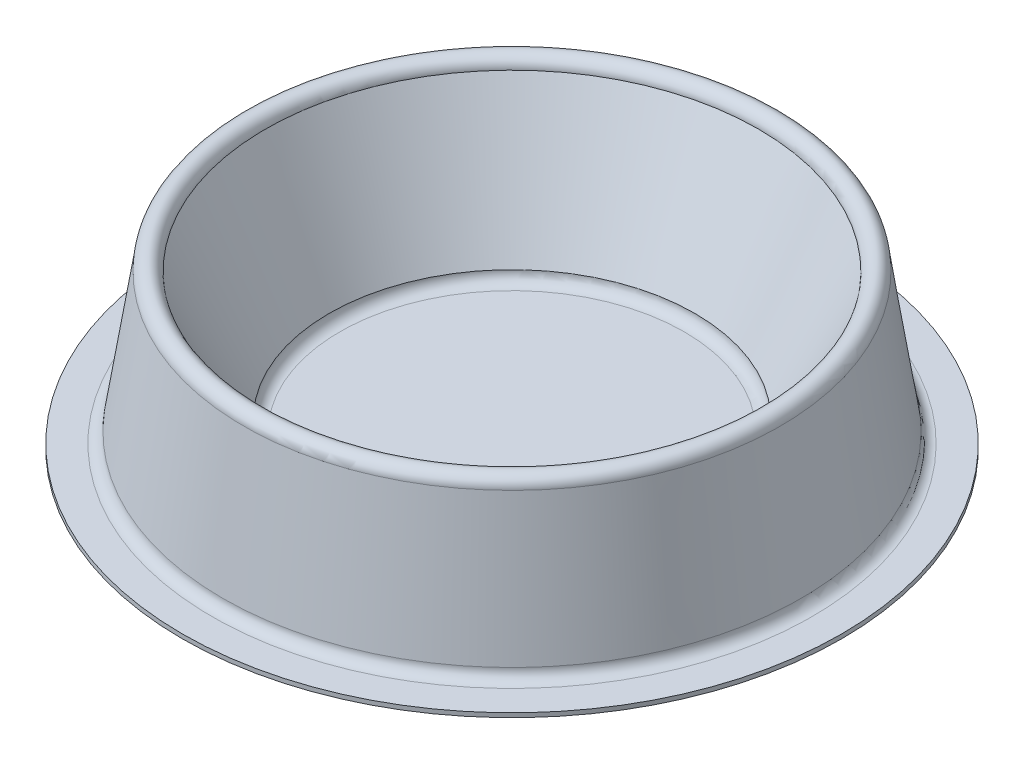
from build123d import *


with BuildPart() as part:
    # Sketch1 → Revolve-Thin1 (revolve)
    with BuildSketch(Plane.XY):
        with BuildLine():
            Line((-27.318946546, 0), (-20.318946546, 0))
            ThreePointArc((-20.318946546, 0), (-18.551179593, 0.732233047), (-17.818946546, 2.5))
            Line((-17.818946546, 2.5), (-12.818946546, 35))
            ThreePointArc((-12.818946546, 35), (-10.318946546, 37.5), (-7.818946546, 35))
            Line((-7.818946546, 35), (7.181053454, 5))
            ThreePointArc((7.181053454, 5), (7.913286502, 3.232233047), (9.681053454, 2.5))
            Line((9.681053454, 2.5), (50.181053454, 2.5))
            Line((50.181053454, 2.5), (50.181053454, 1.5))
            Line((50.181053454, 1.5), (9.681053454, 1.5))
            ThreePointArc((9.681053454, 1.5), (7.297899321, 2.436686446), (6.190327002, 4.745384927))
            Line((6.190327002, 4.745384927), (-8.833337961, 34.792714853))
            ThreePointArc((-8.833337961, 34.792714853), (-10.2484084, 36.498340539), (-11.817458386, 34.933199819))
            Line((-11.817458386, 34.933199819), (-16.819927214, 2.417152435))
            ThreePointArc((-16.819927214, 2.417152435), (-17.873539266, -0.003993458), (-20.318946546, -1))
            Line((-20.318946546, -1), (-27.318946546, -1))
            Line((-27.318946546, -1), (-27.318946546, 0))
        make_face()
    revolve(axis=Axis((50.181053454, 2.5, 0), (0, 1, 0)))


solid = part.part
